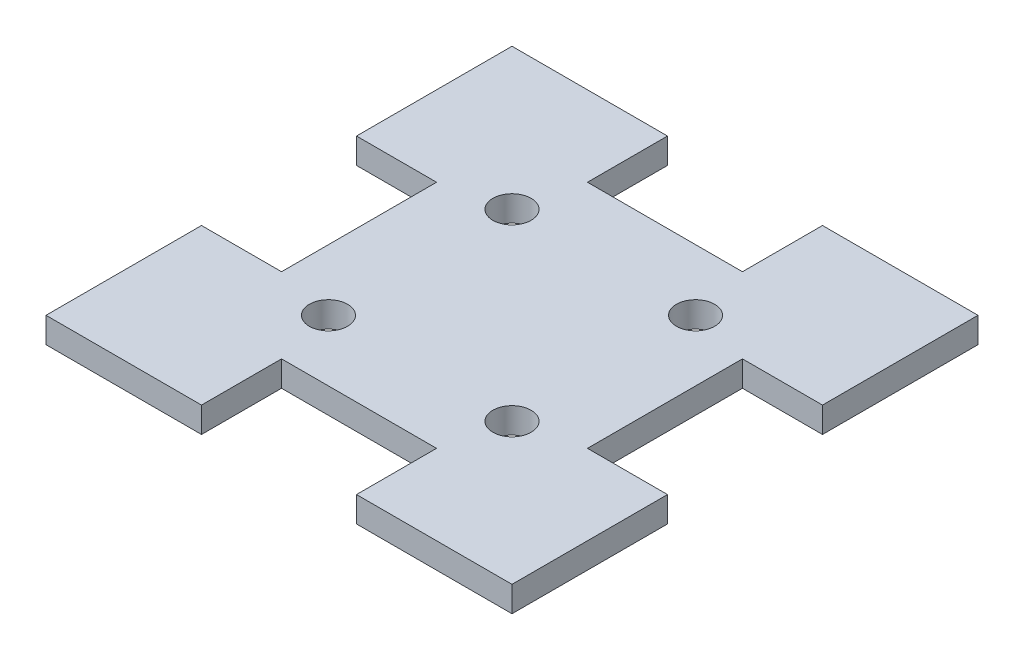
from build123d import *

# Parameters (mm, degrees)
BOSS_EXTRUDE1_DEPTH = 3.175
SKETCH2_R           = 4.7625
CUT_EXTRUDE1_DEPTH  = 7.35


with BuildPart() as part:
    # Sketch1 → Boss-Extrude1 (new body, symmetric)
    with BuildSketch(Plane(origin=(0, 0, 0), x_dir=(1, 0, 0), z_dir=(0, 1, 0))):
        Polygon((-58.039, -19.304), (-58.039, -58.039), (-19.304, -58.039), (-19.304, -38.1), (19.304, -38.1), (19.304, -58.039), (58.039, -58.039), (58.039, -19.304), (38.1, -19.304), (38.1, 19.304), (58.039, 19.304), (58.039, 58.039), (19.304, 58.039), (19.304, 38.1), (-19.304, 38.1), (-19.304, 58.039), (-58.039, 58.039), (-58.039, 19.304), (-38.1, 19.304), (-38.1, -19.304), align=None)
    extrude(amount=BOSS_EXTRUDE1_DEPTH, both=True)

    # Sketch2 → Cut-Extrude1 (cut, through all)
    with BuildSketch(Plane(origin=(0, 3.175, 0), x_dir=(1, 0, 0), z_dir=(0, 1, 0))):
        with Locations((-22.86, 22.86)):
            Circle(SKETCH2_R)
        with Locations((-22.86, -22.86)):
            Circle(SKETCH2_R)
        with Locations((22.86, -22.86)):
            Circle(SKETCH2_R)
        with Locations((22.86, 22.86)):
            Circle(SKETCH2_R)
    extrude(amount=-CUT_EXTRUDE1_DEPTH, mode=Mode.SUBTRACT)


solid = part.part
